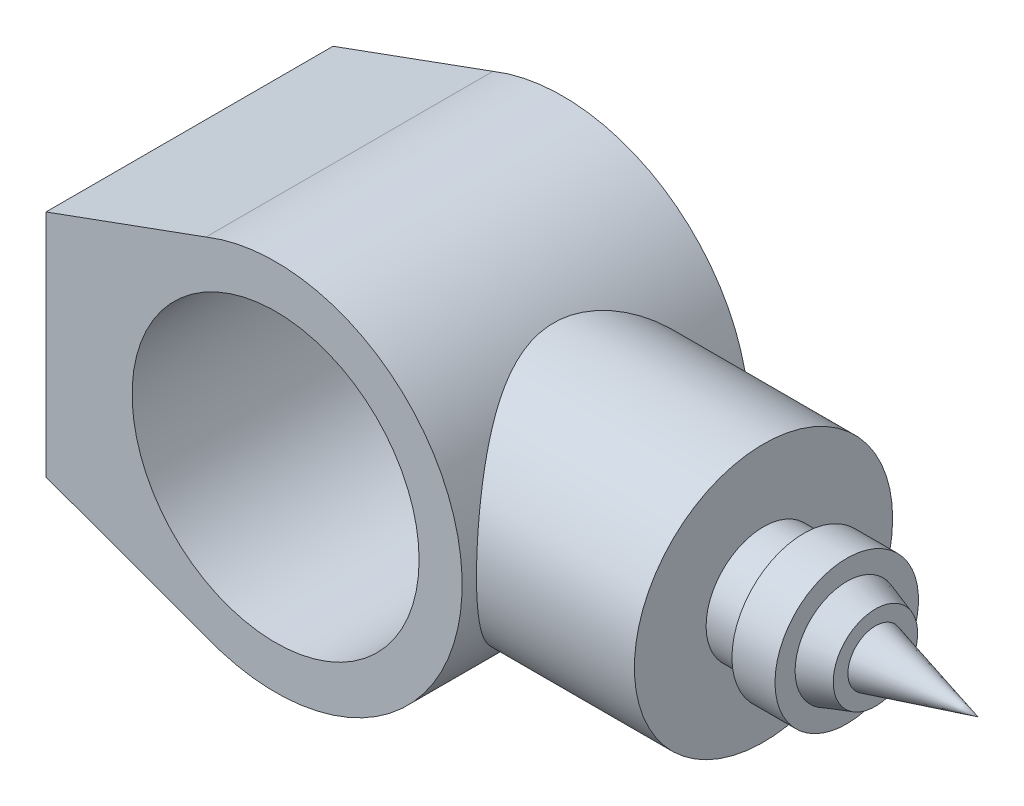
from build123d import *

# Parameters (mm, degrees)
SKETCH1_R           = 50
BOSS_EXTRUDE1_DEPTH = 50
BOSS_EXTRUDE2_REACH = 202
SKETCH2_R           = 45


with BuildPart() as part:
    # Sketch1 → Boss-Extrude1 (new body, symmetric)
    with BuildSketch(Plane.XY):
        with BuildLine():
            Line((-80, -40), (-80, 40))
            Line((-80, 40), (-24.258721248, 60.303519329))
            ThreePointArc((-24.258721248, 60.303519329), (65, 0), (-24.258721248, -60.303519329))
            Line((-24.258721248, -60.303519329), (-80, -40))
        make_face()
        Circle(SKETCH1_R, mode=Mode.SUBTRACT)
    extrude(amount=BOSS_EXTRUDE1_DEPTH, both=True)

    # Sketch2 → Boss-Extrude2 (add, up to next)
    with BuildSketch(Plane(origin=(120, 0, 0), x_dir=(0, 0, -1), z_dir=(1, 0, 0)), mode=Mode.PRIVATE) as boss_extrude2_sk1:
        Circle(SKETCH2_R)
    boss_extrude2_tool1 = extrude(boss_extrude2_sk1.sketch, amount=-BOSS_EXTRUDE2_REACH, mode=Mode.PRIVATE) - part.part
    add(boss_extrude2_tool1.solids().sort_by_distance((120, 0, 0))[0])

    # Sketch3 → Revolve1 (revolve)
    with BuildSketch(Plane.XY):
        Polygon((120, 0), (120, -20), (134, -20), (134, -25), (149, -25), (149, -18), (159, -14.701335797), (159, -9.588406282), (194.736010759, 0), align=None)
    revolve(axis=Axis((0, 0, 0), (1, 0, 0)))


solid = part.part
